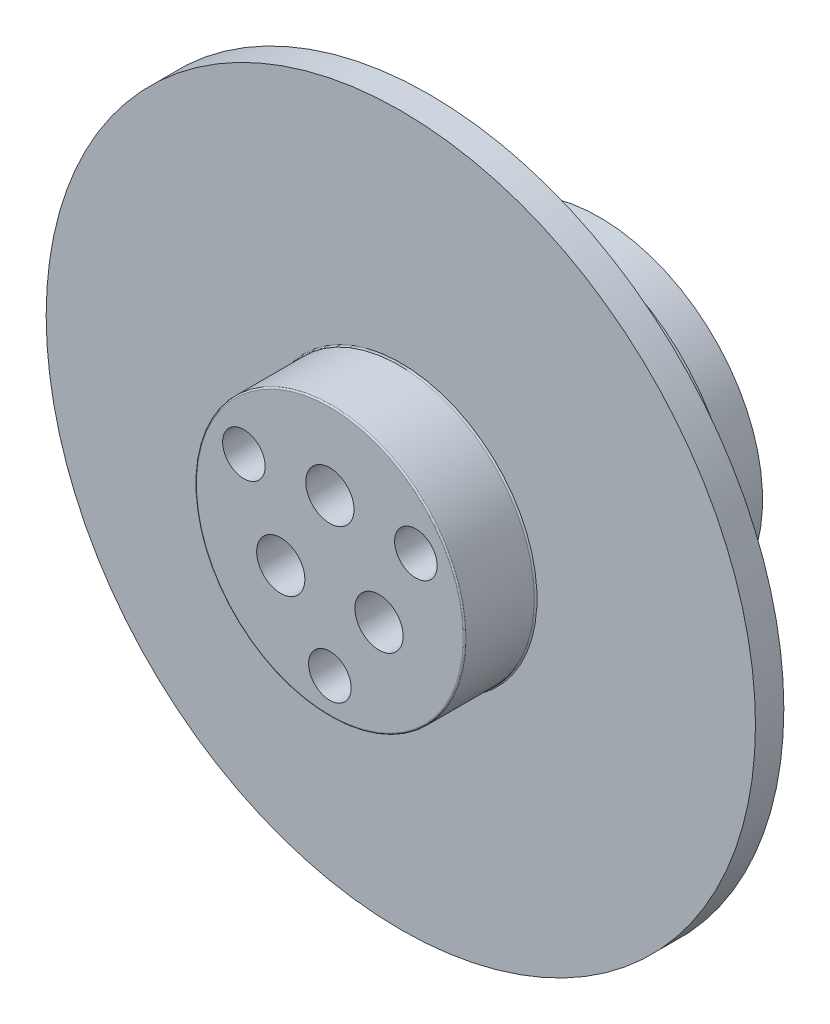
from build123d import *
from build123d.topology import SkipClean

# Parameters (mm, degrees)
SKETCH_2_R                   = 25
SKETCH_2_R_2                 = 10
EXTRUDE_2_DEPTH              = 2
SKETCH_35_R                  = 13.5
EXTRUDE_3_DEPTH              = 2
SKETCH_36_R                  = 12.5
EXTRUDE_4_DEPTH              = 7
HOLE_WIZARD_M3_1_D           = 3.4
HOLE_WIZARD_M3_1_CBORE_D     = 6.5
HOLE_WIZARD_M3_1_CBORE_DEPTH = 3.4
PATTERN_CIRCULAR_1_COUNT     = 3
PATTERN_CIRCULAR_2_COUNT     = 3
EXTRUDE_START                = 3
SKETCH_53_R                  = 11.5
SKETCH_53_R_2                = 1.65
SKETCH_53_R_3                = 3.25
EXTRUDE_5_DEPTH              = 3
EXTRUDE_START_2              = 7
SKETCH_61_R                  = 10
SKETCH_61_R_2                = 1.7
EXTRUDE_6_DEPTH              = 7
SKETCH_62_R                  = 10
SKETCH_62_R_2                = 9.5
CUT_EXTRUDE_1_DEPTH          = 5
FILLET_1_R                   = 0.1
PATTERN_CIRCULAR_3_COUNT     = 3
PATTERN_CIRCULAR_4_COUNT     = 2


with BuildPart() as part:
    # 스케치2 → 보스-돌출2 (new body)
    with BuildSketch(Plane(origin=(0, 6, 0), x_dir=(1, 0, 0), z_dir=(0, 0, -1))):
        with Locations(Location((0, 6, 0), (0, 0, 180))):
            Circle(SKETCH_2_R)
        with Locations(Location((0, 6, 0), (0, 0, 180))):
            Circle(SKETCH_2_R_2, mode=Mode.SUBTRACT)
    extrude(amount=EXTRUDE_2_DEPTH)

    # 스케치35 → 보스-돌출3 (add)
    with BuildSketch(Plane(origin=(0, 0, -2), x_dir=(-1, 0, 0), z_dir=(0, 0, -1))):
        Circle(SKETCH_35_R)
    extrude(amount=EXTRUDE_3_DEPTH)

    # 스케치36 → 보스-돌출4 (add)
    with BuildSketch(Plane(origin=(0, 0, -4), x_dir=(-1, 0, 0), z_dir=(0, 0, -1))):
        Circle(SKETCH_36_R)
    extrude(amount=EXTRUDE_4_DEPTH)

    # M3 육각 소켓 머리 캡 나사용 카운터보어1 (through all)
    with Locations(Plane(origin=(0, 0, -11), x_dir=(-1, 0, 0), z_dir=(0, 0, -1))):
        with Locations((0, 4)):
            hole_wizard_m3_1 = CounterBoreHole(HOLE_WIZARD_M3_1_D / 2, HOLE_WIZARD_M3_1_CBORE_D / 2, HOLE_WIZARD_M3_1_CBORE_DEPTH)

    # 원형 패턴1: M3 육각 소켓 머리 캡 나사용 카운터보어1 ×3 about axis
    pattern_circular_1_axis = Axis((0, 0, 0), (0, 0, 1))
    for i in range(1, PATTERN_CIRCULAR_1_COUNT):
        add(hole_wizard_m3_1.rotate(pattern_circular_1_axis, i * 360 / PATTERN_CIRCULAR_1_COUNT), mode=Mode.SUBTRACT)

    # 스케치52 → M4 탭을 위한 탭 드릴1 (revolve, cut)
    with BuildSketch(Plane(origin=(0, -7, -11), x_dir=(0, 1, 0), z_dir=(1, 0, 0))):
        Polygon((0, 0), (0, 5.991420021), (1.65, 5), (1.65, 0), align=None)
    hole_wizard_m4_1 = revolve(axis=Axis((0, -7, -17.35), (0, 0, 1)), mode=Mode.SUBTRACT)

    # 원형 패턴2: M4 탭을 위한 탭 드릴1 ×3 about axis
    pattern_circular_2_axis = Axis((0, 0, 0), (0, 0, 1))
    for i in range(1, PATTERN_CIRCULAR_2_COUNT):
        add(hole_wizard_m4_1.rotate(pattern_circular_2_axis, i * 360 / PATTERN_CIRCULAR_2_COUNT), mode=Mode.SUBTRACT)

    # 스케치53 → 보스-돌출5 (add)
    with SkipClean():  # the faces are left unmerged after this step: merging them gives an invalid solid
        with BuildSketch(Plane(origin=(0, 0, -11), x_dir=(-1, 0, 0), z_dir=(0, 0, -1)).offset(EXTRUDE_START)):
            Circle(SKETCH_53_R)
            with Locations((6.062177826, 3.5)):
                Circle(SKETCH_53_R_2, mode=Mode.SUBTRACT)
            with Locations((0, -7)):
                Circle(SKETCH_53_R_2, mode=Mode.SUBTRACT)
            with Locations((3.464101615, -2)):
                Circle(SKETCH_53_R_3, mode=Mode.SUBTRACT)
            with Locations((0, 4)):
                Circle(SKETCH_53_R_3, mode=Mode.SUBTRACT)
            with Locations((-3.464101615, -2)):
                Circle(SKETCH_53_R_3, mode=Mode.SUBTRACT)
            with Locations((-6.062177826, 3.5)):
                Circle(SKETCH_53_R_2, mode=Mode.SUBTRACT)
        extrude(amount=-EXTRUDE_5_DEPTH)

    # 스케치61 → 보스-돌출6 (add)
    with BuildSketch(Plane.XY.offset(-2).offset(EXTRUDE_START_2)):
        with Locations(Location((0, 0, 0), (0, 0, 180))):
            Circle(SKETCH_61_R)
        with Locations(Location((-3.464101615, -2, 0), (0, 0, 180))):
            Circle(SKETCH_61_R_2, mode=Mode.SUBTRACT)
        with Locations(Location((3.464101615, -2, 0), (0, 0, 180))):
            Circle(SKETCH_61_R_2, mode=Mode.SUBTRACT)
        with Locations(Location((0, 4, 0), (0, 0, 180))):
            Circle(SKETCH_61_R_2, mode=Mode.SUBTRACT)
    extrude(amount=-EXTRUDE_6_DEPTH)

    # 스케치62 → 컷-돌출1 (cut)
    with BuildSketch(Plane.XY.offset(5)):
        Circle(SKETCH_62_R)
        Circle(SKETCH_62_R_2, mode=Mode.SUBTRACT)
    extrude(amount=-CUT_EXTRUDE_1_DEPTH, mode=Mode.SUBTRACT)

    # 필렛1
    fillet_1_edges = [part.edges().sort_by_distance(p)[0] for p in [
        (-9.5, 0, 0),
        (-9.5, 0, 5),
    ]]
    fillet(fillet_1_edges, radius=FILLET_1_R)

    # 스케치67 → Ø3.0mm 맞춤핀 구멍1 (revolve, cut)
    with BuildSketch(Plane(origin=(0, -7, 5), x_dir=(0, -1, 0), z_dir=(1, 0, 0))):
        Polygon((0, 0), (0, 5.901290929), (1.5, 5), (1.5, 0), align=None)
    f_3_0mm_1 = revolve(axis=Axis((0, -7, 11.35), (0, 0, -1)), mode=Mode.SUBTRACT)

    # 원형 패턴3: Ø3.0mm 맞춤핀 구멍1 ×3 about axis
    pattern_circular_3_axis = Axis((0, 0, 0), (0, 0, 1))
    for i in range(1, PATTERN_CIRCULAR_3_COUNT):
        add(f_3_0mm_1.rotate(pattern_circular_3_axis, i * 360 / PATTERN_CIRCULAR_3_COUNT), mode=Mode.SUBTRACT)

    # 스케치79 → Ø3.0mm 맞춤핀 구멍4 (revolve, cut)
    with BuildSketch(Plane(origin=(-4.25, 7.361215932, -14), x_dir=(0, 1, 0), z_dir=(1, 0, 0))):
        Polygon((0, 0), (0, 5.901290929), (1.5, 5), (1.5, 0), align=None)
    f_3_0mm_4 = revolve(axis=Axis((-4.25, 7.361215932, -20.35), (0, 0, 1)), mode=Mode.SUBTRACT)

    # 원형 패턴4: Ø3.0mm 맞춤핀 구멍4 ×2 about axis
    pattern_circular_4_axis = Axis((0, 0, 0), (0, 0, 1))
    for i in range(1, PATTERN_CIRCULAR_4_COUNT):
        add(f_3_0mm_4.rotate(pattern_circular_4_axis, i * 360 / PATTERN_CIRCULAR_4_COUNT), mode=Mode.SUBTRACT)


solid = part.part
